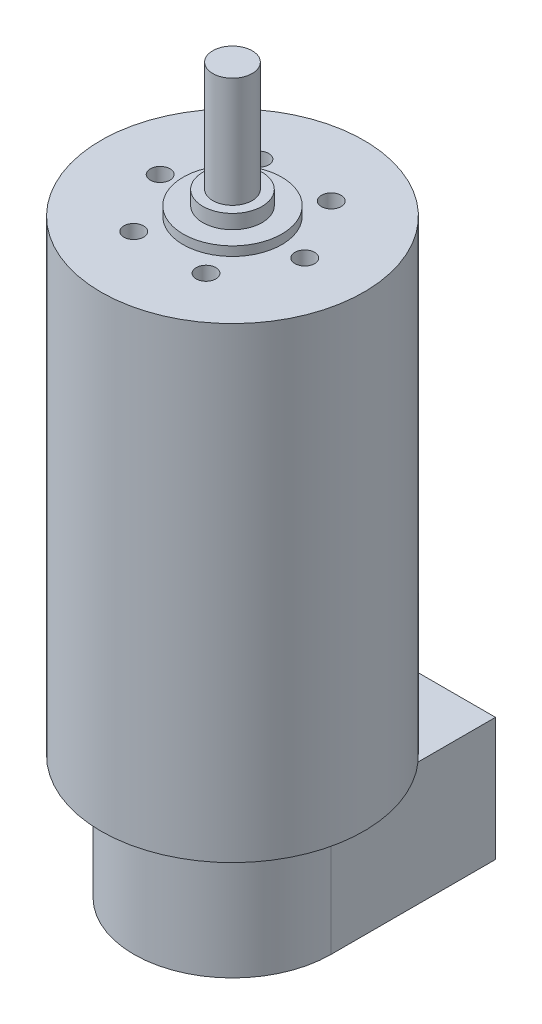
from build123d import *

# Parameters (mm, degrees)
SKETCH1_R           = 20
BOSS_EXTRUDE1_DEPTH = 71
SKETCH2_R           = 7.5
BOSS_EXTRUDE2_DEPTH = 1.4
SKETCH3_R           = 4.5
BOSS_EXTRUDE3_DEPTH = 2.15
SKETCH4_R           = 3
BOSS_EXTRUDE4_DEPTH = 16.75
SKETCH5_R           = 1.5
CUT_EXTRUDE1_DEPTH  = 5
CIRPATTERN1_COUNT   = 6
BOSS_EXTRUDE5_DEPTH = 18.73


with BuildPart() as part:
    # Sketch1 → Boss-Extrude1 (new body)
    with BuildSketch(Plane(origin=(0, 0, 0), x_dir=(1, 0, 0), z_dir=(0, 1, 0))):
        Circle(SKETCH1_R)
    extrude(amount=BOSS_EXTRUDE1_DEPTH)

    # Sketch2 → Boss-Extrude2 (add)
    with BuildSketch(Plane(origin=(0, 71, 0), x_dir=(1, 0, 0), z_dir=(0, 1, 0))):
        Circle(SKETCH2_R)
    extrude(amount=BOSS_EXTRUDE2_DEPTH)

    # Sketch3 → Boss-Extrude3 (add)
    with BuildSketch(Plane(origin=(0, 72.4, 0), x_dir=(1, 0, 0), z_dir=(0, 1, 0))):
        Circle(SKETCH3_R)
    extrude(amount=BOSS_EXTRUDE3_DEPTH)

    # Sketch4 → Boss-Extrude4 (add)
    with BuildSketch(Plane(origin=(0, 74.55, 0), x_dir=(1, 0, 0), z_dir=(0, 1, 0))):
        Circle(SKETCH4_R)
    extrude(amount=BOSS_EXTRUDE4_DEPTH)

    # Sketch5 → Cut-Extrude1 (cut)
    with BuildSketch(Plane(origin=(0, 71, 0), x_dir=(1, 0, 0), z_dir=(0, 1, 0))):
        with Locations((-11, 0)):
            Circle(SKETCH5_R)
    cut_extrude1 = extrude(amount=-CUT_EXTRUDE1_DEPTH, mode=Mode.SUBTRACT)

    # CirPattern1: Cut-Extrude1 ×6 about axis
    cirpattern1_axis = Axis((0, 0, 0), (0, 1, 0))
    for i in range(1, CIRPATTERN1_COUNT):
        add(cut_extrude1.rotate(cirpattern1_axis, i * 360 / CIRPATTERN1_COUNT), mode=Mode.SUBTRACT)

    # Sketch6 → Boss-Extrude5 (add)
    with BuildSketch(Plane(origin=(0, 0, 0), x_dir=(-1, 0, 0), z_dir=(0, -1, 0))):
        with BuildLine():
            Line((15, 0), (15, 25))
            Line((15, 25), (-15, 25))
            Line((-15, 25), (-15, 0))
            ThreePointArc((-15, 0), (0, -15), (15, 0))
        make_face()
    extrude(amount=BOSS_EXTRUDE5_DEPTH)


solid = part.part
